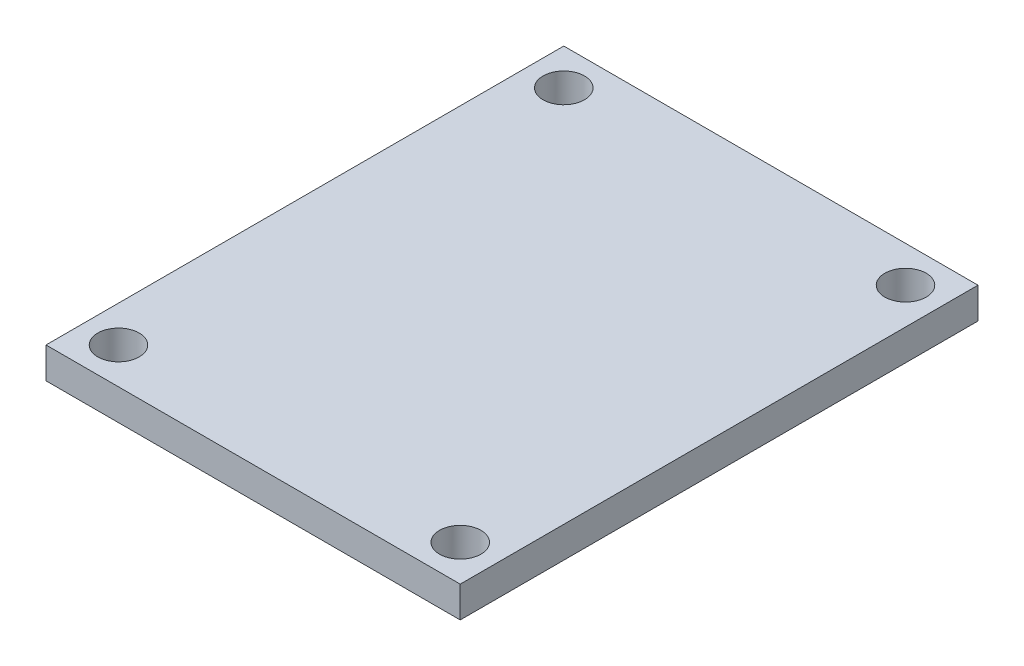
from build123d import *

# Parameters (mm, degrees)
CROQUIS2_W              = 508
CROQUIS2_H              = 635
SALIENTE_EXTRUIR2_DEPTH = 38.1
CROQUIS3_R              = 25.4
CORTAR_EXTRUIR1_DEPTH   = 38.1


with BuildPart() as part:
    # Croquis2 → Saliente-Extruir2 (new body)
    with BuildSketch(Plane(origin=(0, 0, 0), x_dir=(1, 0, 0), z_dir=(0, 1, 0))):
        Rectangle(CROQUIS2_W, CROQUIS2_H)
    extrude(amount=SALIENTE_EXTRUIR2_DEPTH)

    # Croquis3 → Cortar-Extruir1 (cut)
    with BuildSketch(Plane(origin=(0, 38.1, 0), x_dir=(1, 0, 0), z_dir=(0, 1, 0))):
        with Locations((-209.55, 273.05)):
            Circle(CROQUIS3_R)
        with Locations((209.55, 273.05)):
            Circle(CROQUIS3_R)
        with Locations((209.55, -273.05)):
            Circle(CROQUIS3_R)
        with Locations((-209.55, -273.05)):
            Circle(CROQUIS3_R)
    extrude(amount=-CORTAR_EXTRUIR1_DEPTH, mode=Mode.SUBTRACT)


solid = part.part
